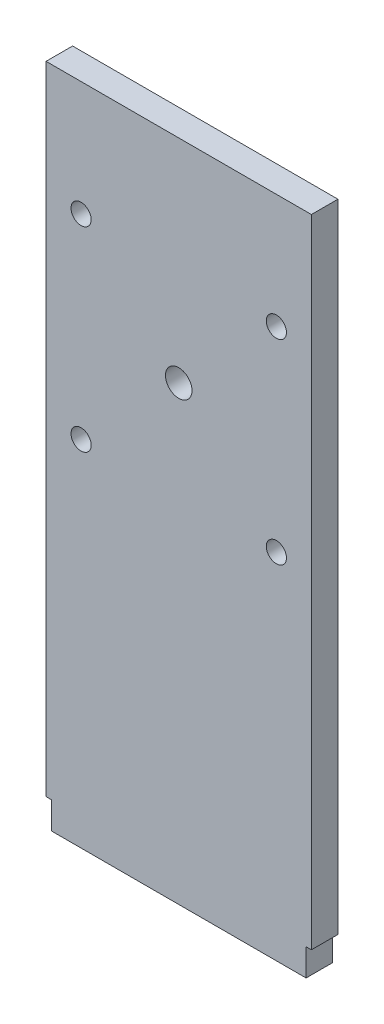
from build123d import *

# Parameters (mm, degrees)
SKETCH2_W           = 63.5
SKETCH2_H           = 158.877
SKETCH2_R           = 2.413
SKETCH2_R_2         = 3.175
BOSS_EXTRUDE1_DEPTH = 6.35
SKETCH3_W           = 1.27
SKETCH3_H           = 6.477
CUT_EXTRUDE1_DEPTH  = 7.35


with BuildPart() as part:
    # Sketch2 → Boss-Extrude1 (new body)
    with BuildSketch(Plane.XY):
        with Locations((31.75, 79.4385)):
            Rectangle(SKETCH2_W, SKETCH2_H)
        with Locations((8.382, 131.445)):
            Circle(SKETCH2_R, mode=Mode.SUBTRACT)
        with Locations((55.118, 131.445)):
            Circle(SKETCH2_R, mode=Mode.SUBTRACT)
        with Locations((55.118, 84.709)):
            Circle(SKETCH2_R, mode=Mode.SUBTRACT)
        with Locations((8.382, 84.709)):
            Circle(SKETCH2_R, mode=Mode.SUBTRACT)
        with Locations((31.75, 108.077)):
            Circle(SKETCH2_R_2, mode=Mode.SUBTRACT)
    extrude(amount=BOSS_EXTRUDE1_DEPTH)

    # Sketch3 → Cut-Extrude1 (cut, through all)
    with BuildSketch(Plane.XY.offset(6.35)):
        with Locations((0.635, 3.2385)):
            Rectangle(SKETCH3_W, SKETCH3_H)
        with Locations((62.865, 3.2385)):
            Rectangle(SKETCH3_W, SKETCH3_H)
    extrude(amount=-CUT_EXTRUDE1_DEPTH, mode=Mode.SUBTRACT)


solid = part.part
